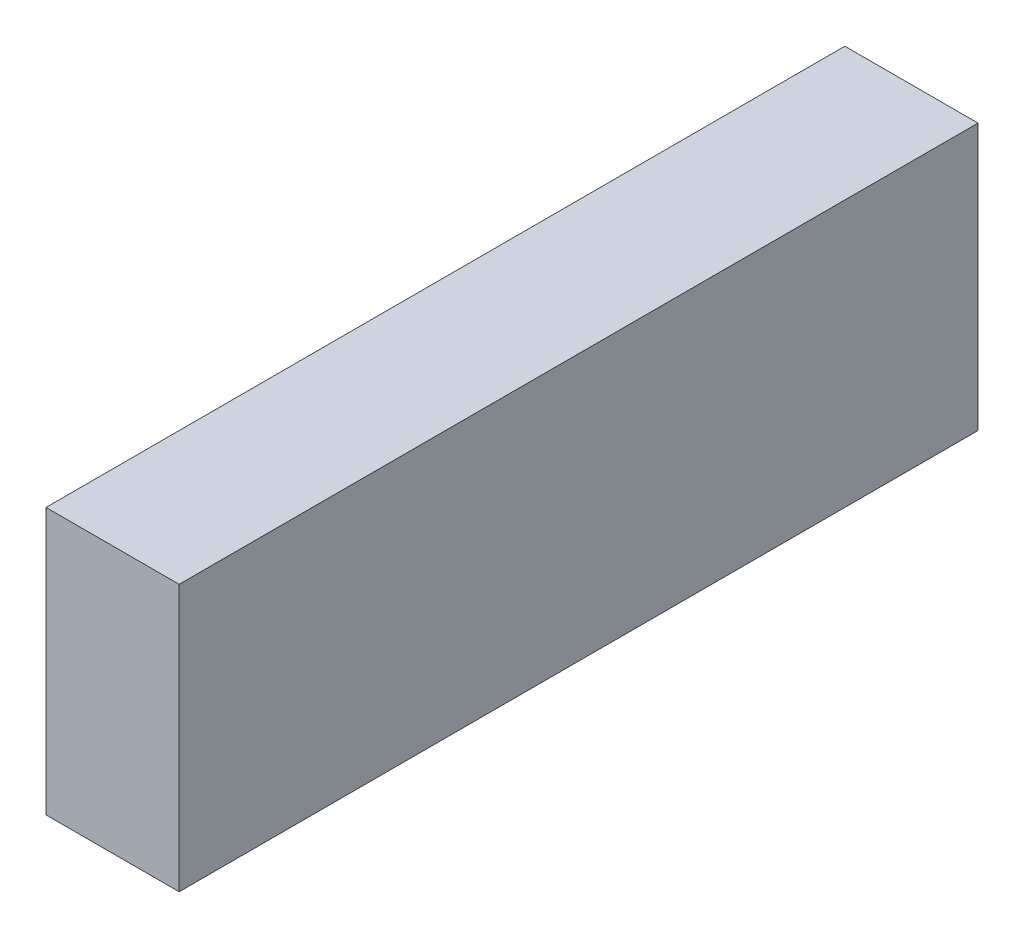
from build123d import *

# Parameters (mm, degrees)
BOSS_EXTRUDE1_DEPTH = 69
SKETCH4_W           = 15
SKETCH4_H           = 188.2
BOSS_EXTRUDE2_DEPTH = 61.9
BOSS_EXTRUDE3_DEPTH = 20.4
FILLET1_R           = 10
SKETCH6_W           = 6000
SKETCH6_H           = 2000
BOSS_EXTRUDE4_DEPTH = 1000
SKETCH8_W           = 880
SKETCH8_H           = 440
BOSS_EXTRUDE5_DEPTH = 220


with BuildPart() as part:
    # Sketch2 → Boss-Extrude1 (new body, symmetric)
    with BuildSketch(Plane(origin=(0, 0, 0), x_dir=(0, 0, -1), z_dir=(1, 0, 0))):
        with BuildLine():
            Line((-262.793626597, 0), (0, 0))
            Line((0, 0), (203.2, 0))
            Line((203.2, 0), (203.2, 81.9))
            Line((203.2, 81.9), (188.2, 81.9))
            Line((188.2, 81.9), (188.2, 20))
            Line((188.2, 20), (0, 20))
            Line((0, 20), (0, 133.7))
            Line((0, 133.7), (-115, 133.7))
            Line((-115, 133.7), (-171.193830238, 94.352656466))
            Line((-171.193830238, 94.352656466), (-262.793626597, 81.479144628))
            Line((-262.793626597, 81.479144628), (-262.793626597, 31.479144628))
            ThreePointArc((-262.793626597, 31.479144628), (-272.644060375, 15.739572314), (-262.793626597, 0))
        make_face()
    extrude(amount=BOSS_EXTRUDE1_DEPTH, both=True)

    # Sketch4 → Boss-Extrude2 (add)
    with BuildSketch(Plane(origin=(0, 20, 0), x_dir=(1, 0, 0), z_dir=(0, 1, 0))):
        with Locations((61.5, 94.1)):
            Rectangle(SKETCH4_W, SKETCH4_H)
    boss_extrude2 = extrude(amount=BOSS_EXTRUDE2_DEPTH)

    # Mirror1: Boss-Extrude2 across plane
    add(boss_extrude2.mirror(Plane(origin=(0, 0, 0), x_dir=(0, 0, 1), z_dir=(1, 0, 0))))

    # Sketch5 → Boss-Extrude3 (add)
    with BuildSketch(Plane(origin=(69, 0, 0), x_dir=(0, 0, -1), z_dir=(1, 0, 0))):
        with BuildLine():
            Line((-224.944060375, 0), (-160.344060375, 0))
            ThreePointArc((-160.344060375, 0), (-192.644060375, -32.3), (-224.944060375, 0))
        make_face()
        with BuildLine():
            Line((28.055939625, 0), (92.655939625, 0))
            ThreePointArc((92.655939625, 0), (60.355939625, -32.3), (28.055939625, 0))
        make_face()
    boss_extrude3 = extrude(amount=-BOSS_EXTRUDE3_DEPTH)

    # Mirror2: Boss-Extrude3 across plane
    add(boss_extrude3.mirror(Plane(origin=(0, 0, 0), x_dir=(0, 0, 1), z_dir=(1, 0, 0))))

    # Fillet1
    fillet1_edges = [part.edges().sort_by_distance(p)[0] for p in [
        (0, 31.479144628, 262.793626597),
        (0, 81.479144628, 262.793626597),
        (0, 94.352656466, 171.193830238),
        (0, 133.7, 115),
        (0, 133.7, 0),
    ]]
    fillet(fillet1_edges, radius=FILLET1_R)


with BuildPart() as body_2:
    # Sketch6 → Boss-Extrude4 (new body)
    with BuildSketch(Plane(origin=(0, 0, 0), x_dir=(0, 0, -1), z_dir=(1, 0, 0))):
        with Locations((807.355939625, 967.7)):
            Rectangle(SKETCH6_W, SKETCH6_H)
    extrude(amount=BOSS_EXTRUDE4_DEPTH)


with BuildPart() as body_3:
    # Sketch8 → Boss-Extrude5 (new body)
    with BuildSketch(Plane(origin=(0, 0, 0), x_dir=(0, 0, -1), z_dir=(1, 0, 0))):
        with Locations((47.355939625, 187.7)):
            Rectangle(SKETCH8_W, SKETCH8_H)
    extrude(amount=BOSS_EXTRUDE5_DEPTH)


solid = Compound([part.part, body_2.part, body_3.part])
